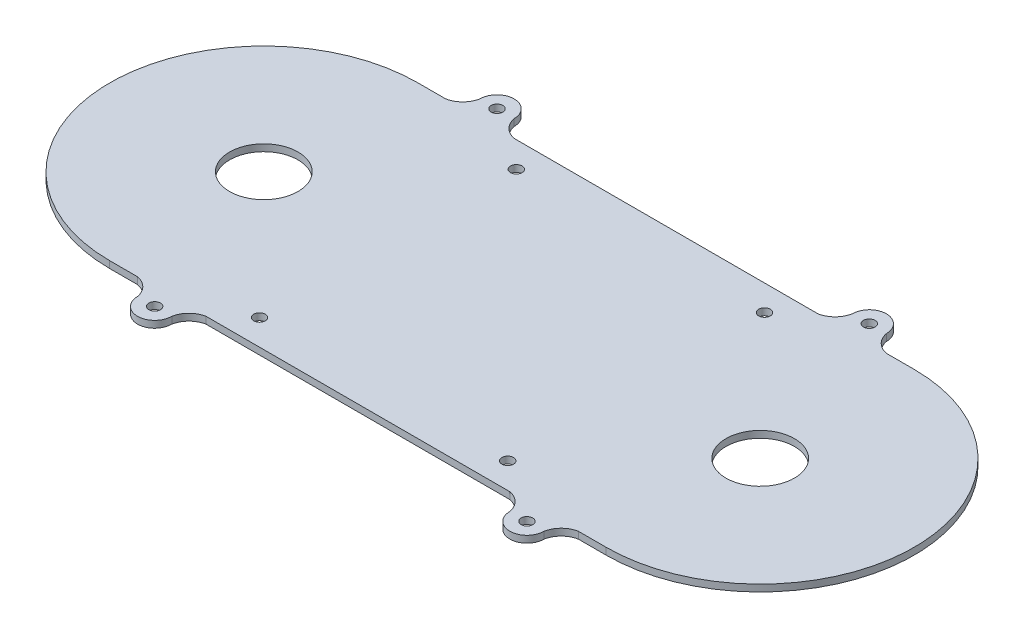
from build123d import *

# Parameters (mm, degrees)
SKETCH1_R           = 1.7
BOSS_EXTRUDE1_DEPTH = 2
SKETCH2_R           = 1.7
CUT_EXTRUDE1_DEPTH  = 4
SKETCH5_R           = 10
CUT_EXTRUDE2_DEPTH  = 10
SKETCH7_R           = 5
BOSS_EXTRUDE3_DEPTH = 3


with BuildPart() as part:
    # Sketch1 → Boss-Extrude1 (new body)
    with BuildSketch(Plane(origin=(0, 0, 0), x_dir=(1, 0, 0), z_dir=(0, 1, 0))):
        with BuildLine():
            Line((0, 45), (8.125, 45))
            ThreePointArc((8.125, 45), (11.393102806, 46.731897194), (13.125, 50))
            ThreePointArc((13.125, 50), (18.125, 55), (23.125, 50))
            ThreePointArc((23.125, 50), (24.856897194, 46.731897194), (28.125, 45))
            Line((28.125, 45), (116.875, 45))
            ThreePointArc((116.875, 45), (120.143102806, 46.731897194), (121.875, 50))
            ThreePointArc((121.875, 50), (126.875, 55), (131.875, 50))
            ThreePointArc((131.875, 50), (133.606897194, 46.731897194), (136.875, 45))
            Line((136.875, 45), (145, 45))
            ThreePointArc((145, 45), (190, 0), (145, -45))
            Line((145, -45), (136.875, -45))
            ThreePointArc((136.875, -45), (133.606897194, -46.731897194), (131.875, -50))
            ThreePointArc((131.875, -50), (126.875, -55), (121.875, -50))
            ThreePointArc((121.875, -50), (120.143102806, -46.731897194), (116.875, -45))
            Line((116.875, -45), (28.125, -45))
            ThreePointArc((28.125, -45), (24.856897194, -46.731897194), (23.125, -50))
            ThreePointArc((23.125, -50), (18.125, -55), (13.125, -50))
            ThreePointArc((13.125, -50), (11.393102806, -46.731897194), (8.125, -45))
            Line((8.125, -45), (0, -45))
            ThreePointArc((0, -45), (-45, 0), (0, 45))
        make_face()
        with Locations((108.75, -37.5)):
            Circle(SKETCH1_R, mode=Mode.SUBTRACT)
        with Locations((36.25, -37.5)):
            Circle(SKETCH1_R, mode=Mode.SUBTRACT)
        with Locations((36.25, 37.5)):
            Circle(SKETCH1_R, mode=Mode.SUBTRACT)
        with Locations((108.75, 37.5)):
            Circle(SKETCH1_R, mode=Mode.SUBTRACT)
    extrude(amount=BOSS_EXTRUDE1_DEPTH)

    # Sketch2 → Cut-Extrude1 (cut)
    with BuildSketch(Plane(origin=(0, 2, 0), x_dir=(1, 0, 0), z_dir=(0, 1, 0))):
        with Locations((18.11681751, -49.994200378)):
            Circle(SKETCH2_R)
        with Locations((126.86681751, -49.994200378)):
            Circle(SKETCH2_R)
        with Locations((126.86681751, 49.994200378)):
            Circle(SKETCH2_R)
        with Locations((18.11681751, 49.994200378)):
            Circle(SKETCH2_R)
    extrude(amount=-CUT_EXTRUDE1_DEPTH, mode=Mode.SUBTRACT)

    # Sketch5 → Cut-Extrude2 (cut)
    with BuildSketch(Plane(origin=(0, 2, 0), x_dir=(1, 0, 0), z_dir=(0, 1, 0))):
        Circle(SKETCH5_R)
        with Locations((145, 0)):
            Circle(SKETCH5_R)
    extrude(amount=-CUT_EXTRUDE2_DEPTH, mode=Mode.SUBTRACT)

    # Sketch7 → Boss-Extrude3 (add)
    with BuildSketch(Plane(origin=(0, 0, 0), x_dir=(-1, 0, 0), z_dir=(0, -1, 0))):
        with Locations((-72.5, 0)):
            Circle(SKETCH7_R)
    extrude(amount=BOSS_EXTRUDE3_DEPTH)

    # Sketch9 → Cut-Revolve1 (revolve, cut)
    with BuildSketch(Plane.ZY.offset(-72.5)):
        Polygon((0, 0), (0, -3), (-3, -3), align=None)
    revolve(axis=Axis((72.5, 0, 0), (0, -1, 0)), mode=Mode.SUBTRACT)


solid = part.part
